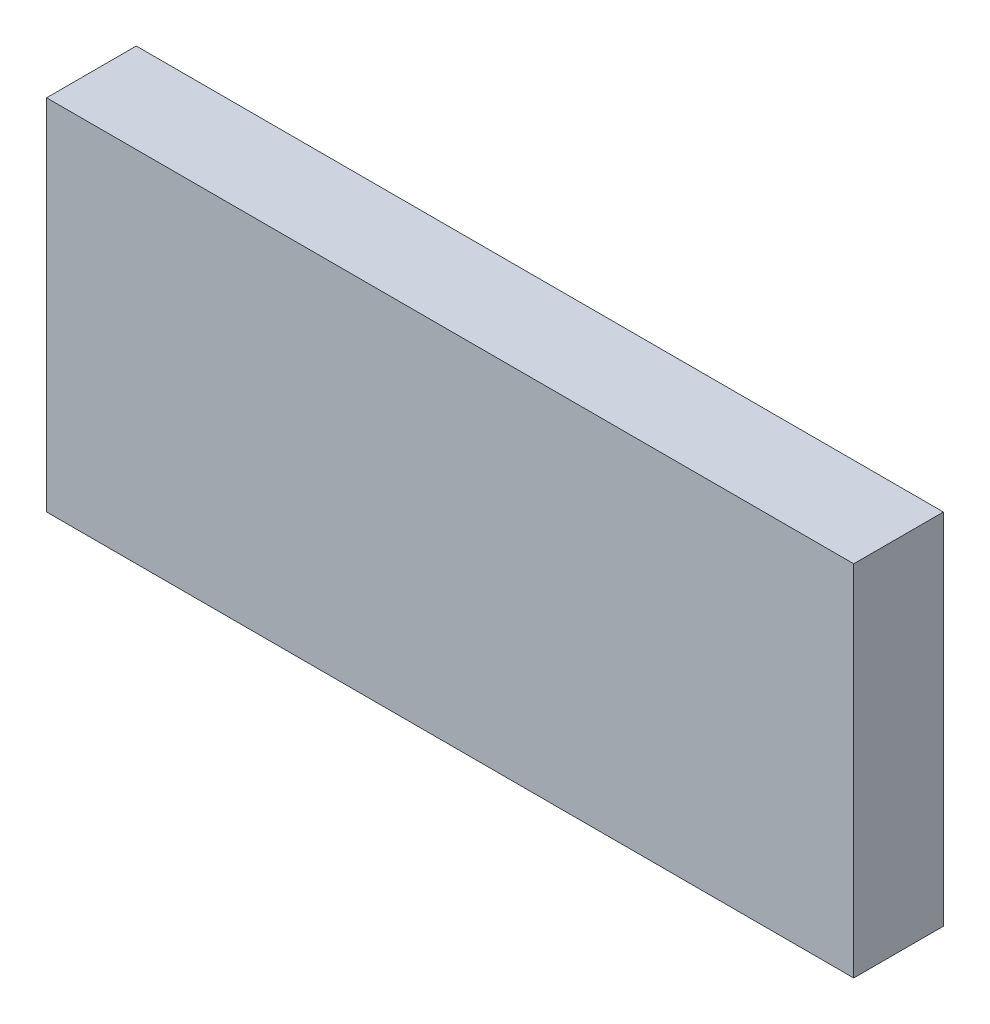
from build123d import *

# Parameters (mm, degrees)
SKETCH1_W           = 22.86
SKETCH1_H           = 10.16
BOSS_EXTRUDE1_DEPTH = 2.54


with BuildPart() as part:
    # Sketch1 → Boss-Extrude1 (new body)
    with BuildSketch(Plane.XY):
        with Locations((11.43, 5.08)):
            Rectangle(SKETCH1_W, SKETCH1_H)
    extrude(amount=BOSS_EXTRUDE1_DEPTH)


solid = part.part
